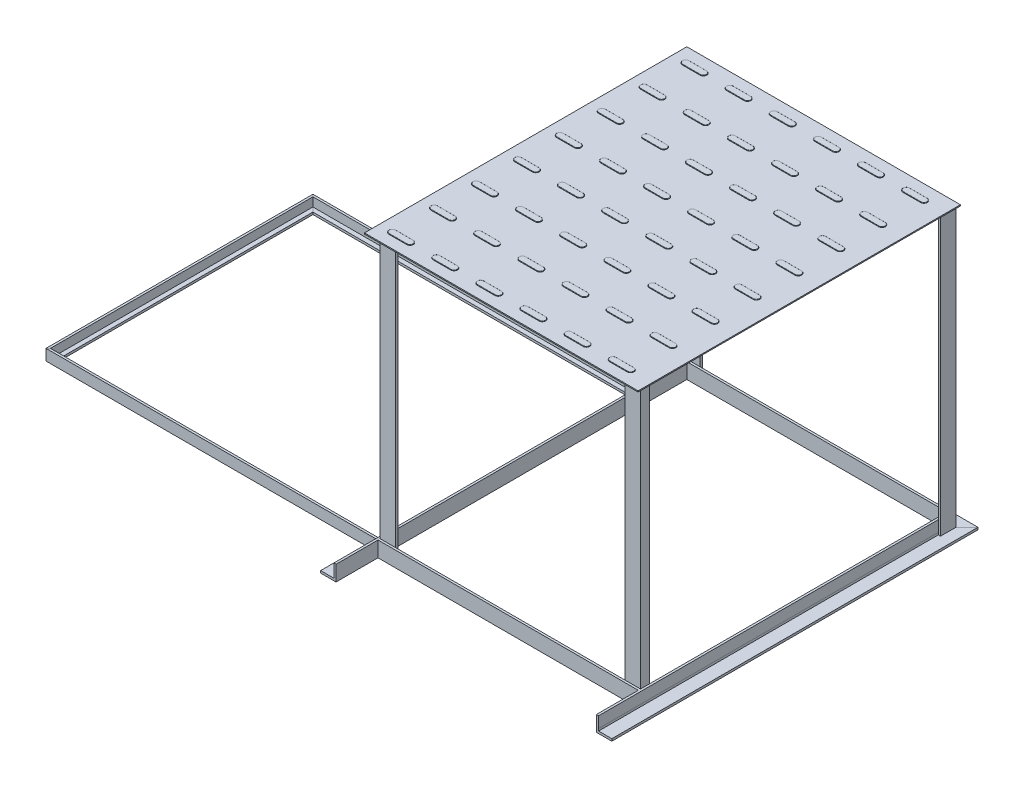
from build123d import *

# Parameters (mm, degrees)
BOSS_EXTRUDE1_DEPTH    = 6
BOSS_EXTRUDE2_DEPTH    = 6
BOSS_EXTRUDE3_DEPTH    = 6
BOSS_EXTRUDE4_DEPTH    = 6
SKETCH26_W             = 124.035096312
SKETCH26_H             = 146.11696487
BOSS_EXTRUDE5_DEPTH    = 0.5
BOSS_EXTRUDE6_DEPTH    = 0.25
FILLET1_R              = 0.125
FILLET2_R              = 0.025
LPATTERN2_COUNT        = 8
LPATTERN2_PITCH        = 19
LPATTERN2_COUNT_DIR2   = 6
LPATTERN2_PITCH_DIR2   = 20
FILLET1_OF_LPATTERN2_R = 0.125
FILLET2_OF_LPATTERN2_R = 0.025


with BuildPart() as part:
    # Sweep1: sweep along a path in Sketch1
    with BuildLine(Plane(origin=(0, 0, 0), x_dir=(1, 0, 0), z_dir=(0, 1, 0))) as sweep1_path:
        Line((0, 0), (-150, 0))
        Line((-150, 0), (-150, -120))
        Line((-150, -120), (0, -120))
    # Sketch2 → Sweep1 (sweep)
    with BuildSketch(Plane.ZY):
        Polygon((-0.5, 2.5), (-0.5, -2.5), (2.5, -2.5), (2.5, -1.5), (0.5, -1.5), (0.5, 2.5), align=None)
    sweep(path=sweep1_path.line, transition=Transition.RIGHT)

    # Sweep4: sweep along a path in Sketch5
    with BuildLine(Plane(origin=(0, 0, 0), x_dir=(1, 0, 0), z_dir=(0, 1, 0))) as sweep4_path:
        Line((0, -140.5), (0, 19.5))
        Line((0, 19.5), (120, 19.5))
        Line((120, 19.5), (120, -140.5))
    # Sketch6 → Sweep4 (sweep)
    with BuildSketch(Plane(origin=(0, 0, 140.5), x_dir=(-1, 0, 0), z_dir=(0, 0, -1))):
        Polygon((0, 3.5), (0, -1.5), (0, -2.5), (6, -2.5), (6, -3.5), (-1, -3.5), (-1, 3.5), align=None)
    sweep(path=sweep4_path.line, transition=Transition.RIGHT)



with BuildPart() as body_2:
    # Sweep5: sweep along a path in Sketch8
    with BuildLine(Plane(origin=(0, 0, 0), x_dir=(0, 0, -1), z_dir=(1, 0, 0))) as sweep5_path:
        Line((19.5, 3.5), (19.5, 123.5))
    # Sketch12 → Sweep5 (sweep)
    with BuildSketch(Plane(origin=(0, 123.5, -19.5), x_dir=(1, 0, 0), z_dir=(0, 1, 0))):
        Polygon((-1, 1), (-1, -6), (0, -6), (0, 0), (6, 0), (6, 1), align=None)
    sweep(path=sweep5_path.line)


with BuildPart() as part_1:
    add(part.part)

    add(body_2.part)  # Boss-Extrude1 merges body 2
    # Sketch13 → Boss-Extrude1 (add)
    with BuildSketch(Plane.XZ.offset(-3.5)):
        Polygon((0, -19.5), (0, -13.5), (-1, -13.5), (-1, -20.5), (6, -20.5), (6, -19.5), align=None)
    extrude(amount=BOSS_EXTRUDE1_DEPTH)



with BuildPart() as body_2_2:
    # Sweep6: sweep along a path in Sketch9
    with BuildLine(Plane.ZY.offset(-120)) as sweep6_path:
        Line((-19.5, 3.5), (-19.5, 123.5))
    # Sketch14 → Sweep6 (sweep)
    with BuildSketch(Plane(origin=(120, 123.5, -19.5), x_dir=(1, 0, 0), z_dir=(0, 1, 0))):
        Polygon((0, 0), (0, -6), (1, -6), (1, 1), (-6, 1), (-6, 0), align=None)
    sweep(path=sweep6_path.line)


with BuildPart() as part_2:
    add(part_1.part)

    add(body_2_2.part)  # Boss-Extrude2 merges body 2 2
    # Sketch15 → Boss-Extrude2 (add)
    with BuildSketch(Plane.XZ.offset(-3.5)):
        Polygon((120, -19.5), (114, -19.5), (114, -20.5), (121, -20.5), (121, -13.5), (120, -13.5), align=None)
    extrude(amount=BOSS_EXTRUDE2_DEPTH)

    # Sweep7: sweep along a path in Sketch18
    with BuildLine(Plane.XY.offset(120.5)) as sweep7_path:
        Line((1, -2.5), (119, -2.5))
    # Sketch19 → Sweep7 (sweep)
    with BuildSketch(Plane(origin=(119, -2.5, 120.5), x_dir=(0, 0, -1), z_dir=(1, 0, 0))):
        Polygon((-1, 6), (-1, -1), (4, -1), (4, 0), (0, 0), (0, 6), align=None)
    sweep(path=sweep7_path.line)



with BuildPart() as body_2_3:
    # Sweep8: sweep along a path in Sketch20
    with BuildLine(Plane(origin=(0, 0, 120.5), x_dir=(-1, 0, 0), z_dir=(0, 0, -1))) as sweep8_path:
        Line((-1, 3.5), (-1, 123.5))
    # Sketch21 → Sweep8 (sweep)
    with BuildSketch(Plane(origin=(1, 123.5, 120.5), x_dir=(1, 0, 0), z_dir=(0, 1, 0))):
        Polygon((0, 4), (0, 0), (7, 0), (7, 1), (1, 1), (1, 4), align=None)
    sweep(path=sweep8_path.line)


with BuildPart() as part_3:
    add(part_2.part)

    add(body_2_3.part)  # Boss-Extrude3 merges body 2 3
    # Sketch22 → Boss-Extrude3 (add)
    with BuildSketch(Plane.XZ.offset(-3.5)):
        Polygon((1, 116.5), (2, 116.5), (2, 119.5), (8, 119.5), (8, 120.5), (1, 120.5), align=None)
    extrude(amount=BOSS_EXTRUDE3_DEPTH)



with BuildPart() as body_2_4:
    # Sweep9: sweep along a path in Sketch23
    with BuildLine(Plane(origin=(0, 0, 120.5), x_dir=(-1, 0, 0), z_dir=(0, 0, -1))) as sweep9_path:
        Line((-119, 3.5), (-119, 123.5))
    # Sketch24 → Sweep9 (sweep)
    with BuildSketch(Plane(origin=(119, 123.5, 120.5), x_dir=(1, 0, 0), z_dir=(0, 1, 0))):
        Polygon((0, 4), (0, 0), (-7, 0), (-7, 1), (-1, 1), (-1, 4), align=None)
    sweep(path=sweep9_path.line)


with BuildPart() as part_4:
    add(part_3.part)

    add(body_2_4.part)  # Boss-Extrude4 merges body 2 4
    # Sketch25 → Boss-Extrude4 (add)
    with BuildSketch(Plane.XZ.offset(-3.5)):
        Polygon((118, 116.5), (119, 116.5), (119, 120.5), (112, 120.5), (112, 119.5), (118, 119.5), align=None)
    extrude(amount=BOSS_EXTRUDE4_DEPTH)

    # Sketch26 → Boss-Extrude5 (add)
    with BuildSketch(Plane(origin=(0, 123.5, 0), x_dir=(1, 0, 0), z_dir=(0, 1, 0))):
        with Locations((59.870866337, -51.411800616)):
            Rectangle(SKETCH26_W, SKETCH26_H)
    extrude(amount=BOSS_EXTRUDE5_DEPTH)

    # Sketch27 → Boss-Extrude6 (add)
    with BuildSketch(Plane(origin=(0, 124, 0), x_dir=(1, 0, 0), z_dir=(0, 1, 0))):
        with BuildLine():
            Line((4, 16.5), (12, 16.5))
            ThreePointArc((12, 16.5), (13.5, 15), (12, 13.5))
            Line((12, 13.5), (4, 13.5))
            ThreePointArc((4, 13.5), (2.5, 15), (4, 16.5))
        make_face()
    boss_extrude6 = extrude(amount=BOSS_EXTRUDE6_DEPTH)

    # Fillet1
    fillet1_edges = [part_4.edges().sort_by_distance(p)[0] for p in [
        (2.5, 124.25, -15),
        (8, 124.25, -13.5),
        (13.5, 124.25, -15),
        (8, 124.25, -16.5),
    ]]
    fillet(fillet1_edges, radius=FILLET1_R)

    # Fillet2
    fillet2_edges = [part_4.edges().sort_by_distance(p)[0] for p in [
        (2.5, 124, -15),
        (8, 124, -13.5),
        (13.5, 124, -15),
        (8, 124, -16.5),
    ]]
    fillet(fillet2_edges, radius=FILLET2_R)

    # LPattern2: Boss-Extrude6 8 × 6
    with Locations(*[(j * LPATTERN2_PITCH_DIR2, 0, i * LPATTERN2_PITCH) for i in range(LPATTERN2_COUNT) for j in range(LPATTERN2_COUNT_DIR2) if (i, j) != (0, 0)]):
        add(boss_extrude6)

    # Fillet1 of LPattern2
    fillet1_of_lpattern2_edges = [part_4.edges().sort_by_distance(p)[0] for p in [
        (22.5, 124.25, -15),
        (28, 124.25, -13.5),
        (33.5, 124.25, -15),
        (28, 124.25, -16.5),
        (42.5, 124.25, -15),
        (48, 124.25, -13.5),
        (53.5, 124.25, -15),
        (48, 124.25, -16.5),
        (62.5, 124.25, -15),
        (68, 124.25, -13.5),
        (73.5, 124.25, -15),
        (68, 124.25, -16.5),
        (82.5, 124.25, -15),
        (88, 124.25, -13.5),
        (93.5, 124.25, -15),
        (88, 124.25, -16.5),
        (102.5, 124.25, -15),
        (108, 124.25, -13.5),
        (113.5, 124.25, -15),
        (108, 124.25, -16.5),
        (2.5, 124.25, 4),
        (8, 124.25, 5.5),
        (13.5, 124.25, 4),
        (8, 124.25, 2.5),
        (22.5, 124.25, 4),
        (28, 124.25, 5.5),
        (33.5, 124.25, 4),
        (28, 124.25, 2.5),
        (42.5, 124.25, 4),
        (48, 124.25, 5.5),
        (53.5, 124.25, 4),
        (48, 124.25, 2.5),
        (62.5, 124.25, 4),
        (68, 124.25, 5.5),
        (73.5, 124.25, 4),
        (68, 124.25, 2.5),
        (82.5, 124.25, 4),
        (88, 124.25, 5.5),
        (93.5, 124.25, 4),
        (88, 124.25, 2.5),
        (102.5, 124.25, 4),
        (108, 124.25, 5.5),
        (113.5, 124.25, 4),
        (108, 124.25, 2.5),
        (2.5, 124.25, 23),
        (8, 124.25, 24.5),
        (13.5, 124.25, 23),
        (8, 124.25, 21.5),
        (22.5, 124.25, 23),
        (28, 124.25, 24.5),
        (33.5, 124.25, 23),
        (28, 124.25, 21.5),
        (42.5, 124.25, 23),
        (48, 124.25, 24.5),
        (53.5, 124.25, 23),
        (48, 124.25, 21.5),
        (62.5, 124.25, 23),
        (68, 124.25, 24.5),
        (73.5, 124.25, 23),
        (68, 124.25, 21.5),
        (82.5, 124.25, 23),
        (88, 124.25, 24.5),
        (93.5, 124.25, 23),
        (88, 124.25, 21.5),
        (102.5, 124.25, 23),
        (108, 124.25, 24.5),
        (113.5, 124.25, 23),
        (108, 124.25, 21.5),
        (2.5, 124.25, 42),
        (8, 124.25, 43.5),
        (13.5, 124.25, 42),
        (8, 124.25, 40.5),
        (22.5, 124.25, 42),
        (28, 124.25, 43.5),
        (33.5, 124.25, 42),
        (28, 124.25, 40.5),
        (42.5, 124.25, 42),
        (48, 124.25, 43.5),
        (53.5, 124.25, 42),
        (48, 124.25, 40.5),
        (62.5, 124.25, 42),
        (68, 124.25, 43.5),
        (73.5, 124.25, 42),
        (68, 124.25, 40.5),
        (82.5, 124.25, 42),
        (88, 124.25, 43.5),
        (93.5, 124.25, 42),
        (88, 124.25, 40.5),
        (102.5, 124.25, 42),
        (108, 124.25, 43.5),
        (113.5, 124.25, 42),
        (108, 124.25, 40.5),
        (2.5, 124.25, 61),
        (8, 124.25, 62.5),
        (13.5, 124.25, 61),
        (8, 124.25, 59.5),
        (22.5, 124.25, 61),
        (28, 124.25, 62.5),
        (33.5, 124.25, 61),
        (28, 124.25, 59.5),
        (42.5, 124.25, 61),
        (48, 124.25, 62.5),
        (53.5, 124.25, 61),
        (48, 124.25, 59.5),
        (62.5, 124.25, 61),
        (68, 124.25, 62.5),
        (73.5, 124.25, 61),
        (68, 124.25, 59.5),
        (82.5, 124.25, 61),
        (88, 124.25, 62.5),
        (93.5, 124.25, 61),
        (88, 124.25, 59.5),
        (102.5, 124.25, 61),
        (108, 124.25, 62.5),
        (113.5, 124.25, 61),
        (108, 124.25, 59.5),
        (2.5, 124.25, 80),
        (8, 124.25, 81.5),
        (13.5, 124.25, 80),
        (8, 124.25, 78.5),
        (22.5, 124.25, 80),
        (28, 124.25, 81.5),
        (33.5, 124.25, 80),
        (28, 124.25, 78.5),
        (42.5, 124.25, 80),
        (48, 124.25, 81.5),
        (53.5, 124.25, 80),
        (48, 124.25, 78.5),
        (62.5, 124.25, 80),
        (68, 124.25, 81.5),
        (73.5, 124.25, 80),
        (68, 124.25, 78.5),
        (82.5, 124.25, 80),
        (88, 124.25, 81.5),
        (93.5, 124.25, 80),
        (88, 124.25, 78.5),
        (102.5, 124.25, 80),
        (108, 124.25, 81.5),
        (113.5, 124.25, 80),
        (108, 124.25, 78.5),
        (2.5, 124.25, 99),
        (8, 124.25, 100.5),
        (13.5, 124.25, 99),
        (8, 124.25, 97.5),
        (22.5, 124.25, 99),
        (28, 124.25, 100.5),
        (33.5, 124.25, 99),
        (28, 124.25, 97.5),
        (42.5, 124.25, 99),
        (48, 124.25, 100.5),
        (53.5, 124.25, 99),
        (48, 124.25, 97.5),
        (62.5, 124.25, 99),
        (68, 124.25, 100.5),
        (73.5, 124.25, 99),
        (68, 124.25, 97.5),
        (82.5, 124.25, 99),
        (88, 124.25, 100.5),
        (93.5, 124.25, 99),
        (88, 124.25, 97.5),
        (102.5, 124.25, 99),
        (108, 124.25, 100.5),
        (113.5, 124.25, 99),
        (108, 124.25, 97.5),
        (2.5, 124.25, 118),
        (8, 124.25, 119.5),
        (13.5, 124.25, 118),
        (8, 124.25, 116.5),
        (22.5, 124.25, 118),
        (28, 124.25, 119.5),
        (33.5, 124.25, 118),
        (28, 124.25, 116.5),
        (42.5, 124.25, 118),
        (48, 124.25, 119.5),
        (53.5, 124.25, 118),
        (48, 124.25, 116.5),
        (62.5, 124.25, 118),
        (68, 124.25, 119.5),
        (73.5, 124.25, 118),
        (68, 124.25, 116.5),
        (82.5, 124.25, 118),
        (88, 124.25, 119.5),
        (93.5, 124.25, 118),
        (88, 124.25, 116.5),
        (102.5, 124.25, 118),
        (108, 124.25, 119.5),
        (113.5, 124.25, 118),
        (108, 124.25, 116.5),
    ]]
    fillet(fillet1_of_lpattern2_edges, radius=FILLET1_OF_LPATTERN2_R)

    # Fillet2 of LPattern2
    fillet2_of_lpattern2_edges = [part_4.edges().sort_by_distance(p)[0] for p in [
        (22.5, 124, -15),
        (28, 124, -13.5),
        (33.5, 124, -15),
        (28, 124, -16.5),
        (42.5, 124, -15),
        (48, 124, -13.5),
        (53.5, 124, -15),
        (48, 124, -16.5),
        (62.5, 124, -15),
        (68, 124, -13.5),
        (73.5, 124, -15),
        (68, 124, -16.5),
        (82.5, 124, -15),
        (88, 124, -13.5),
        (93.5, 124, -15),
        (88, 124, -16.5),
        (102.5, 124, -15),
        (108, 124, -13.5),
        (113.5, 124, -15),
        (108, 124, -16.5),
        (2.5, 124, 4),
        (8, 124, 5.5),
        (13.5, 124, 4),
        (8, 124, 2.5),
        (22.5, 124, 4),
        (28, 124, 5.5),
        (33.5, 124, 4),
        (28, 124, 2.5),
        (42.5, 124, 4),
        (48, 124, 5.5),
        (53.5, 124, 4),
        (48, 124, 2.5),
        (62.5, 124, 4),
        (68, 124, 5.5),
        (73.5, 124, 4),
        (68, 124, 2.5),
        (82.5, 124, 4),
        (88, 124, 5.5),
        (93.5, 124, 4),
        (88, 124, 2.5),
        (102.5, 124, 4),
        (108, 124, 5.5),
        (113.5, 124, 4),
        (108, 124, 2.5),
        (2.5, 124, 23),
        (8, 124, 24.5),
        (13.5, 124, 23),
        (8, 124, 21.5),
        (22.5, 124, 23),
        (28, 124, 24.5),
        (33.5, 124, 23),
        (28, 124, 21.5),
        (42.5, 124, 23),
        (48, 124, 24.5),
        (53.5, 124, 23),
        (48, 124, 21.5),
        (62.5, 124, 23),
        (68, 124, 24.5),
        (73.5, 124, 23),
        (68, 124, 21.5),
        (82.5, 124, 23),
        (88, 124, 24.5),
        (93.5, 124, 23),
        (88, 124, 21.5),
        (102.5, 124, 23),
        (108, 124, 24.5),
        (113.5, 124, 23),
        (108, 124, 21.5),
        (2.5, 124, 42),
        (8, 124, 43.5),
        (13.5, 124, 42),
        (8, 124, 40.5),
        (22.5, 124, 42),
        (28, 124, 43.5),
        (33.5, 124, 42),
        (28, 124, 40.5),
        (42.5, 124, 42),
        (48, 124, 43.5),
        (53.5, 124, 42),
        (48, 124, 40.5),
        (62.5, 124, 42),
        (68, 124, 43.5),
        (73.5, 124, 42),
        (68, 124, 40.5),
        (82.5, 124, 42),
        (88, 124, 43.5),
        (93.5, 124, 42),
        (88, 124, 40.5),
        (102.5, 124, 42),
        (108, 124, 43.5),
        (113.5, 124, 42),
        (108, 124, 40.5),
        (2.5, 124, 61),
        (8, 124, 62.5),
        (13.5, 124, 61),
        (8, 124, 59.5),
        (22.5, 124, 61),
        (28, 124, 62.5),
        (33.5, 124, 61),
        (28, 124, 59.5),
        (42.5, 124, 61),
        (48, 124, 62.5),
        (53.5, 124, 61),
        (48, 124, 59.5),
        (62.5, 124, 61),
        (68, 124, 62.5),
        (73.5, 124, 61),
        (68, 124, 59.5),
        (82.5, 124, 61),
        (88, 124, 62.5),
        (93.5, 124, 61),
        (88, 124, 59.5),
        (102.5, 124, 61),
        (108, 124, 62.5),
        (113.5, 124, 61),
        (108, 124, 59.5),
        (2.5, 124, 80),
        (8, 124, 81.5),
        (13.5, 124, 80),
        (8, 124, 78.5),
        (22.5, 124, 80),
        (28, 124, 81.5),
        (33.5, 124, 80),
        (28, 124, 78.5),
        (42.5, 124, 80),
        (48, 124, 81.5),
        (53.5, 124, 80),
        (48, 124, 78.5),
        (62.5, 124, 80),
        (68, 124, 81.5),
        (73.5, 124, 80),
        (68, 124, 78.5),
        (82.5, 124, 80),
        (88, 124, 81.5),
        (93.5, 124, 80),
        (88, 124, 78.5),
        (102.5, 124, 80),
        (108, 124, 81.5),
        (113.5, 124, 80),
        (108, 124, 78.5),
        (2.5, 124, 99),
        (8, 124, 100.5),
        (13.5, 124, 99),
        (8, 124, 97.5),
        (22.5, 124, 99),
        (28, 124, 100.5),
        (33.5, 124, 99),
        (28, 124, 97.5),
        (42.5, 124, 99),
        (48, 124, 100.5),
        (53.5, 124, 99),
        (48, 124, 97.5),
        (62.5, 124, 99),
        (68, 124, 100.5),
        (73.5, 124, 99),
        (68, 124, 97.5),
        (82.5, 124, 99),
        (88, 124, 100.5),
        (93.5, 124, 99),
        (88, 124, 97.5),
        (102.5, 124, 99),
        (108, 124, 100.5),
        (113.5, 124, 99),
        (108, 124, 97.5),
        (2.5, 124, 118),
        (8, 124, 119.5),
        (13.5, 124, 118),
        (8, 124, 116.5),
        (22.5, 124, 118),
        (28, 124, 119.5),
        (33.5, 124, 118),
        (28, 124, 116.5),
        (42.5, 124, 118),
        (48, 124, 119.5),
        (53.5, 124, 118),
        (48, 124, 116.5),
        (62.5, 124, 118),
        (68, 124, 119.5),
        (73.5, 124, 118),
        (68, 124, 116.5),
        (82.5, 124, 118),
        (88, 124, 119.5),
        (93.5, 124, 118),
        (88, 124, 116.5),
        (102.5, 124, 118),
        (108, 124, 119.5),
        (113.5, 124, 118),
        (108, 124, 116.5),
    ]]
    fillet(fillet2_of_lpattern2_edges, radius=FILLET2_OF_LPATTERN2_R)


solid = part_4.part
